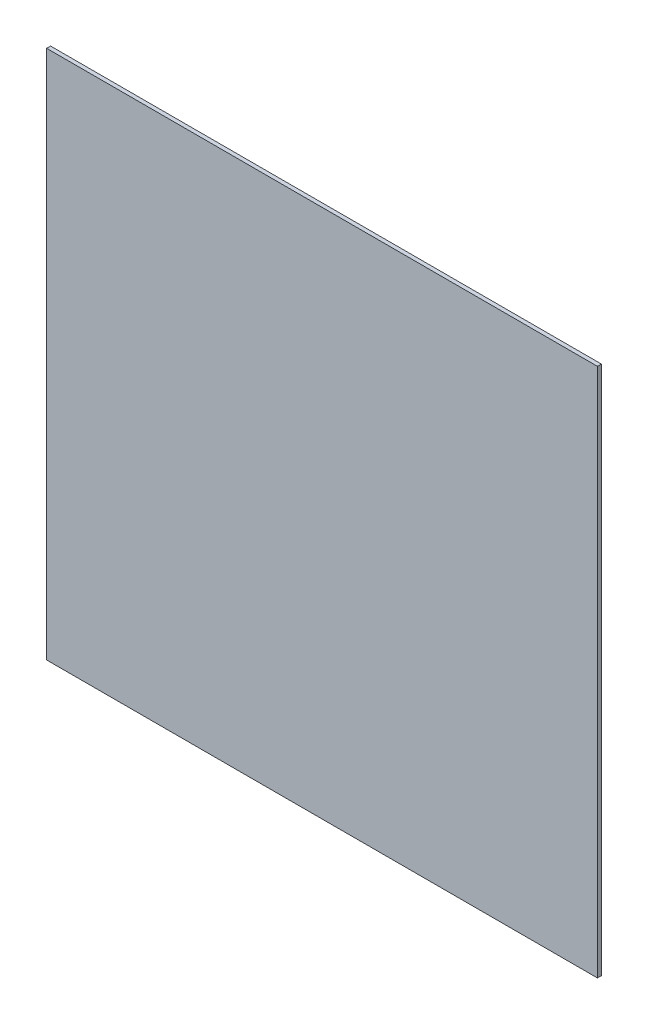
from build123d import *

# Parameters (mm, degrees)
SKETCH1_W           = 417.322
SKETCH1_H           = 401.32
BOSS_EXTRUDE1_DEPTH = 2.9972


with BuildPart() as part:
    # Sketch1 → Boss-Extrude1 (new body)
    with BuildSketch(Plane.XY):
        Rectangle(SKETCH1_W, SKETCH1_H)
    extrude(amount=BOSS_EXTRUDE1_DEPTH)


solid = part.part
